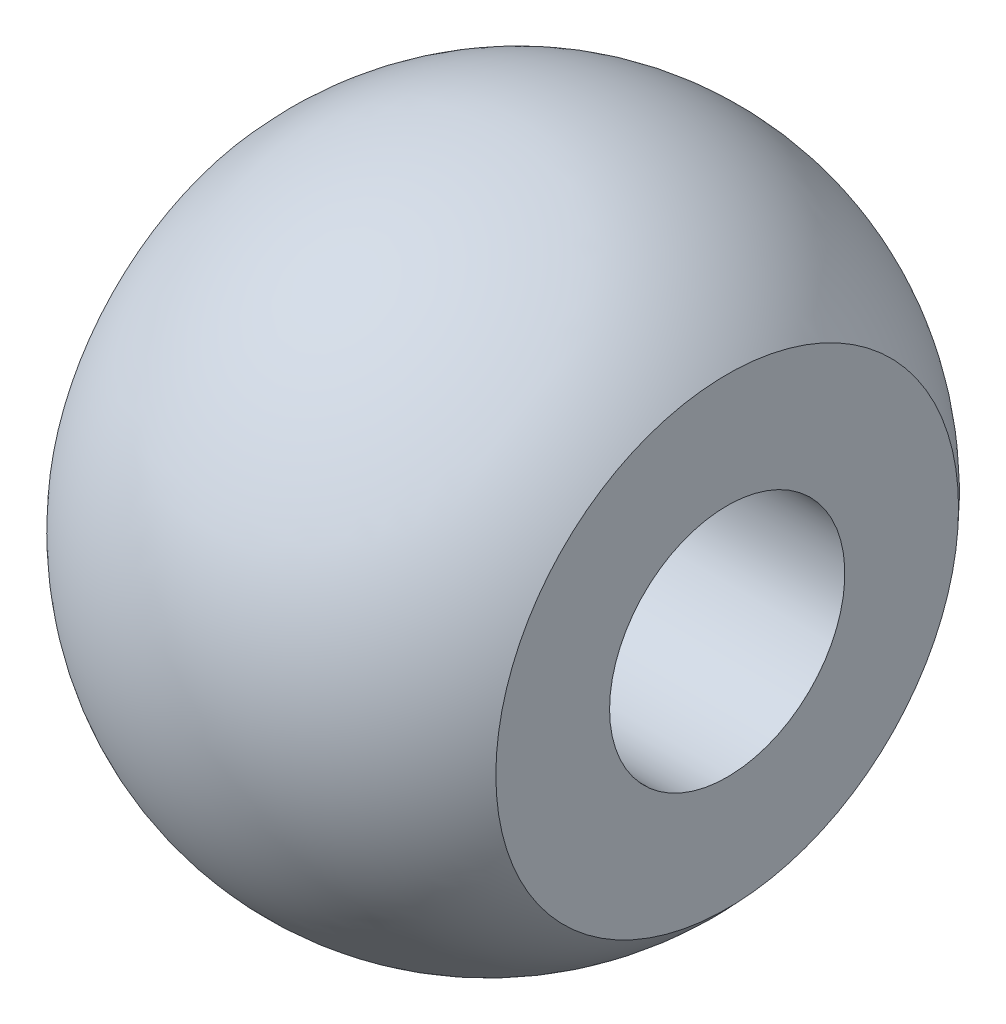
from build123d import *


with BuildPart() as part:
    # Sketch1 → Revolve1 (revolve)
    with BuildSketch(Plane.XY):
        with BuildLine():
            Line((-2.087915852, 2.361347416), (5.912084148, 2.361347416))
            Line((5.912084148, 2.361347416), (5.912084148, 4.644848214))
            ThreePointArc((5.912084148, 4.644848214), (1.412084148, 6.676221247), (-3.087915852, 4.644848214))
            Line((-3.087915852, 4.644848214), (-3.087915852, 3.16576247))
            Line((-3.087915852, 3.16576247), (-2.087915852, 2.361347416))
        make_face()
    revolve(axis=Axis((-2.802478252, 0, 0), (1, 0, 0)))


solid = part.part
